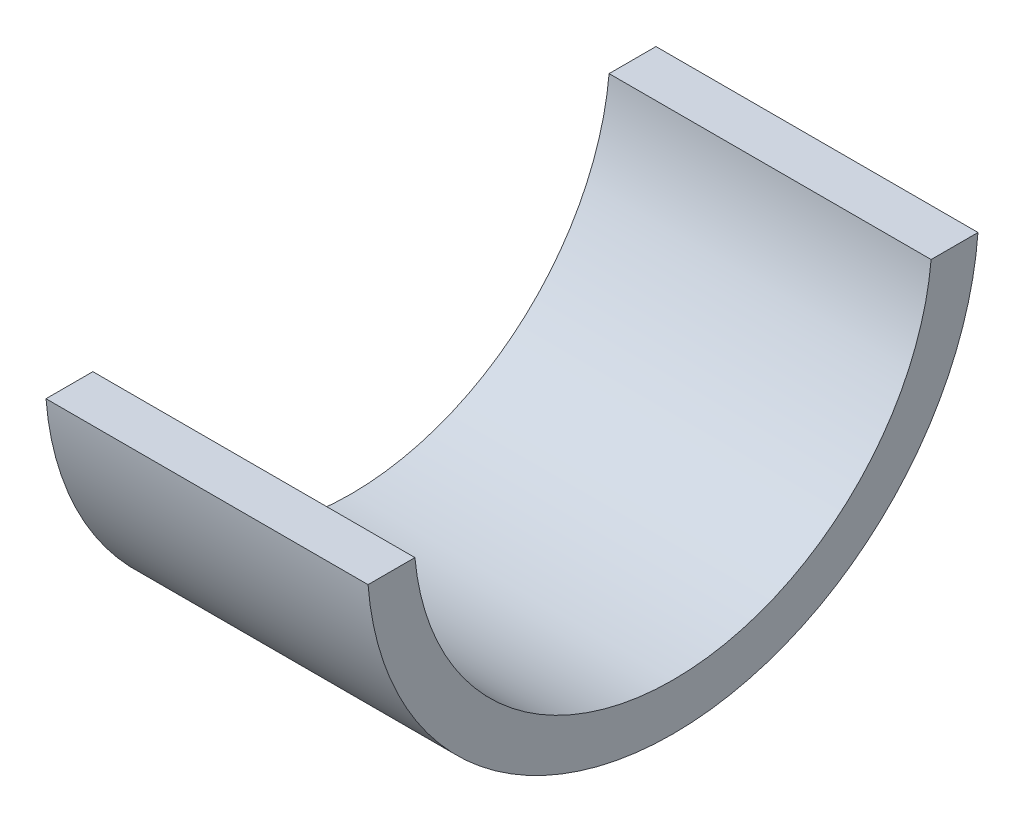
from build123d import *

# Parameters (mm, degrees)
BOSS_EXTRUDE1_DEPTH = 25.4


with BuildPart() as part:
    # Sketch1 → Boss-Extrude1 (new body)
    with BuildSketch(Plane(origin=(0, 0, 0), x_dir=(0, 0, -1), z_dir=(1, 0, 0))):
        with BuildLine():
            Line((-24.054685095, -1.905), (-20.358064348, -1.905))
            ThreePointArc((-20.358064348, -1.905), (0, -20.447), (20.358064348, -1.905))
            Line((20.358064348, -1.905), (24.054685095, -1.905))
            ThreePointArc((24.054685095, -1.905), (0, -24.13), (-24.054685095, -1.905))
        make_face()
    extrude(amount=BOSS_EXTRUDE1_DEPTH)


solid = part.part
